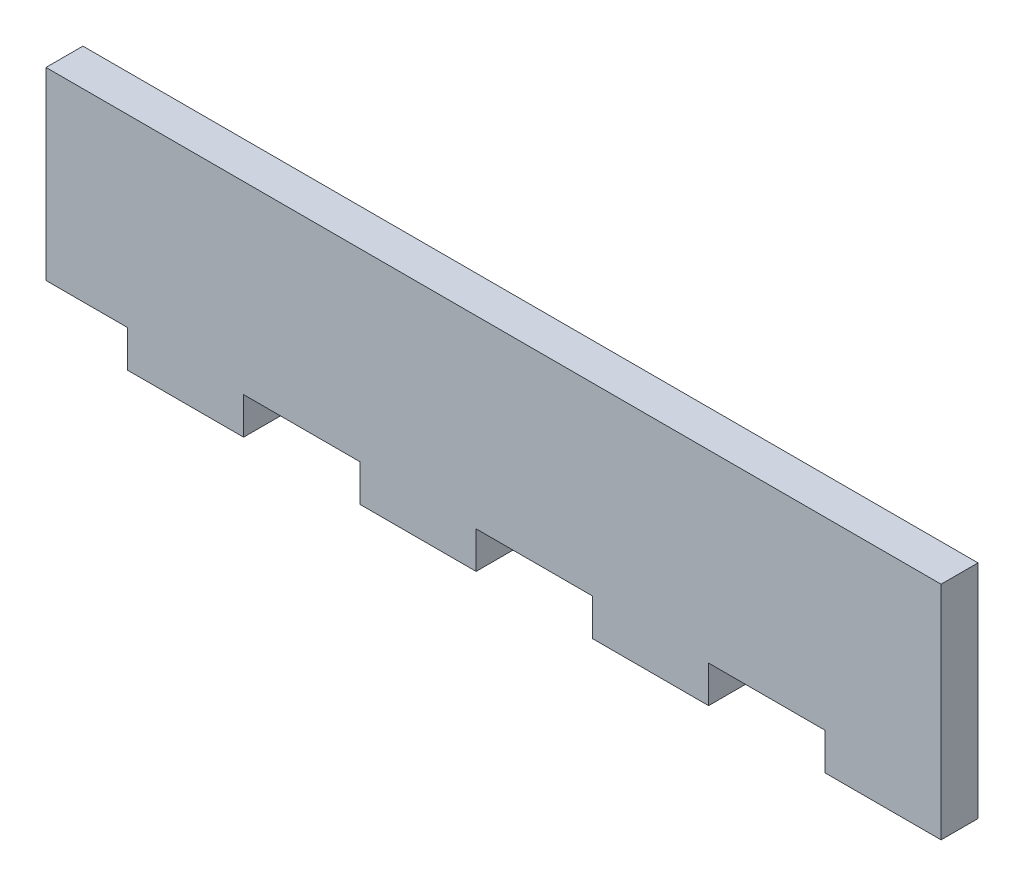
from build123d import *

# Parameters (mm, degrees)
SKETCH1_W           = 3.175
SKETCH1_H           = 15.875
BOSS_EXTRUDE1_DEPTH = 77
SKETCH2_W           = 10
SKETCH2_H           = 3.175
BOSS_EXTRUDE2_DEPTH = 3.175


with BuildPart() as part:
    # Sketch1 → Boss-Extrude1 (new body)
    with BuildSketch(Plane(origin=(0, 0, 0), x_dir=(0, 0, -1), z_dir=(1, 0, 0))):
        with Locations((-0.564444444, 7.9375)):
            Rectangle(SKETCH1_W, SKETCH1_H)
    extrude(amount=BOSS_EXTRUDE1_DEPTH)

    # Sketch2 → Boss-Extrude2 (add)
    with BuildSketch(Plane(origin=(0, 0, -1.023055556), x_dir=(-1, 0, 0), z_dir=(0, 0, -1))):
        with Locations((-52, -1.5875)):
            Rectangle(SKETCH2_W, SKETCH2_H)
        with Locations((-72, -1.5875)):
            Rectangle(SKETCH2_W, SKETCH2_H)
        with Locations((-32, -1.5875)):
            Rectangle(SKETCH2_W, SKETCH2_H)
        with Locations((-12, -1.5875)):
            Rectangle(SKETCH2_W, SKETCH2_H)
    extrude(amount=-BOSS_EXTRUDE2_DEPTH)


solid = part.part
